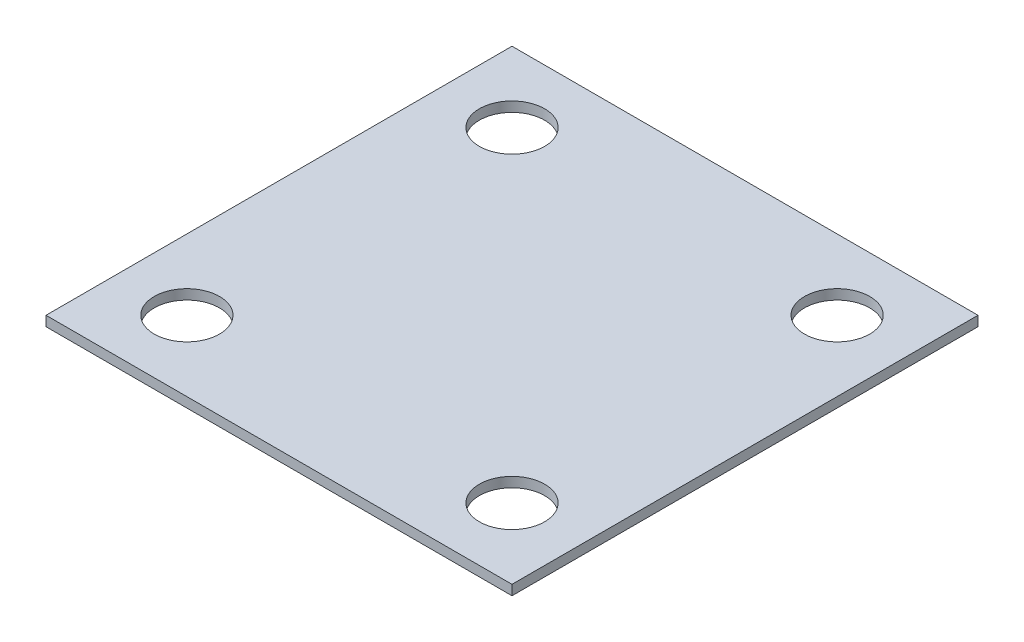
from build123d import *

# Parameters (mm, degrees)
SKETCH1_W           = 75
SKETCH1_H           = 75
SKETCH1_R           = 5.25
BOSS_EXTRUDE1_DEPTH = 1.6


with BuildPart() as part:
    # Sketch1 → Boss-Extrude1 (new body)
    with BuildSketch(Plane(origin=(0, 0, 0), x_dir=(1, 0, 0), z_dir=(0, 1, 0))):
        Rectangle(SKETCH1_W, SKETCH1_H)
        with Locations((-26.1629, -26.1629)):
            Circle(SKETCH1_R, mode=Mode.SUBTRACT)
        with Locations((26.163103615, -26.1629)):
            Circle(SKETCH1_R, mode=Mode.SUBTRACT)
        with Locations((-26.1629, 26.1629)):
            Circle(SKETCH1_R, mode=Mode.SUBTRACT)
        with Locations((26.163103615, 26.1629)):
            Circle(SKETCH1_R, mode=Mode.SUBTRACT)
    extrude(amount=BOSS_EXTRUDE1_DEPTH)


solid = part.part
